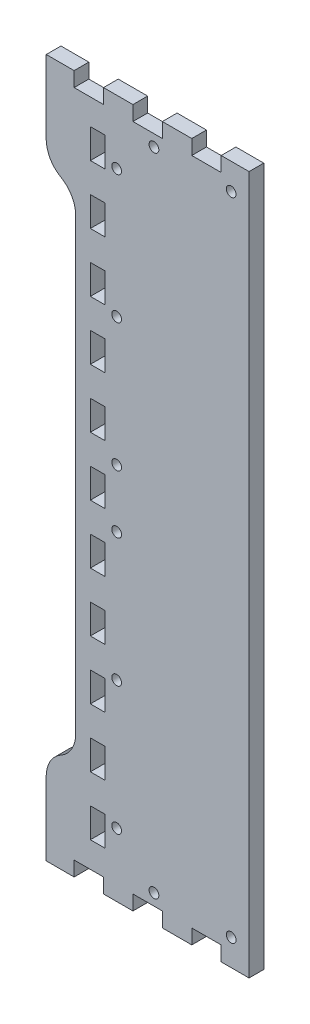
from build123d import *

# Parameters (mm, degrees)
BOSS_EXTRUDE1_DEPTH   = 5.715
F_6_CLEARANCE_HOLE1_D = 3.7973


with BuildPart() as part:
    # Model → Boss-Extrude1 (new body)
    with BuildSketch(Plane.XY):
        Polygon((953.262, 22.8575), (964.099, 22.8575), (964.099, 28.5722), (975.526, 28.5722), (975.526, 22.8575), (986.956, 22.8575), (986.956, 28.5722), (998.386, 28.5722), (998.386, 22.8575), (1009.82, 22.8575), (1009.82, 28.5722), (1021.25, 28.5722), (1021.25, 22.8575), (1032.08, 22.8575), (1032.08, 28.5722), (1032.08, 288.572), (1032.08, 294.287), (1021.25, 294.287), (1021.25, 288.572), (1009.82, 288.572), (1009.82, 294.287), (998.386, 294.287), (998.386, 288.572), (986.956, 288.572), (986.956, 294.287), (975.526, 294.287), (975.526, 288.572), (964.099, 288.572), (964.099, 294.287), (953.262, 294.287), (953.262, 288.572), (953.262, 265.712), (953.262, 265.339), (953.361, 264.218), (953.654, 262.755), (954.133, 261.342), (954.606, 260.321), (954.793, 259.997), (954.888, 259.836), (955.192, 259.36), (955.626, 258.753), (956.098, 258.175), (956.61, 257.631), (957.153, 257.121), (957.732, 256.647), (958.338, 256.211), (958.815, 255.907), (958.977, 255.814), (959.139, 255.721), (959.612, 255.418), (960.222, 254.981), (960.801, 254.507), (961.344, 253.997), (961.856, 253.453), (962.328, 252.876), (962.766, 252.268), (963.069, 251.792), (963.161, 251.63), (963.348, 251.307), (963.824, 250.286), (964.304, 248.874), (964.593, 247.41), (964.692, 246.29), (964.692, 245.915), (964.692, 71.2294), (964.692, 70.8561), (964.593, 69.7357), (964.304, 68.272), (963.824, 66.8595), (963.348, 65.8386), (963.161, 65.5147), (963.069, 65.3535), (962.766, 64.878), (962.328, 64.2705), (961.856, 63.693), (961.344, 63.1486), (960.801, 62.6389), (960.222, 62.1647), (959.612, 61.728), (959.139, 61.4246), (958.977, 61.3311), (958.815, 61.2373), (958.338, 60.9353), (957.732, 60.4986), (957.153, 60.0244), (956.61, 59.5147), (956.098, 58.9703), (955.626, 58.3928), (955.192, 57.7854), (954.888, 57.3098), (954.793, 57.1472), (954.606, 56.8247), (954.133, 55.8038), (953.654, 54.3913), (953.361, 52.9276), (953.262, 51.8072), (953.262, 51.4325), (953.262, 28.5722), align=None)
        Polygon((970.407, 272.872), (970.407, 278.587), (976.122, 278.587), (976.122, 267.158), (970.407, 267.158), align=None, mode=Mode.SUBTRACT)
        Polygon((970.407, 250.012), (970.407, 255.728), (976.122, 255.728), (976.122, 244.297), (970.407, 244.297), align=None, mode=Mode.SUBTRACT)
        Polygon((970.407, 227.153), (970.407, 232.868), (976.122, 232.868), (976.122, 221.437), (970.407, 221.437), align=None, mode=Mode.SUBTRACT)
        Polygon((970.407, 204.293), (970.407, 210.008), (976.122, 210.008), (976.122, 198.578), (970.407, 198.578), align=None, mode=Mode.SUBTRACT)
        Polygon((970.407, 181.433), (970.407, 187.147), (976.122, 187.147), (976.122, 175.718), (970.407, 175.718), align=None, mode=Mode.SUBTRACT)
        Polygon((970.407, 158.572), (970.407, 164.287), (976.122, 164.287), (976.122, 152.858), (970.407, 152.858), align=None, mode=Mode.SUBTRACT)
        Polygon((970.407, 135.712), (970.407, 141.428), (976.122, 141.428), (976.122, 129.997), (970.407, 129.997), align=None, mode=Mode.SUBTRACT)
        Polygon((970.407, 112.853), (970.407, 118.568), (976.122, 118.568), (976.122, 107.137), (970.407, 107.137), align=None, mode=Mode.SUBTRACT)
        Polygon((970.407, 89.9929), (970.407, 95.7076), (976.122, 95.7076), (976.122, 84.2779), (970.407, 84.2779), align=None, mode=Mode.SUBTRACT)
        Polygon((970.407, 67.1326), (970.407, 72.8472), (976.122, 72.8472), (976.122, 61.4179), (970.407, 61.4179), align=None, mode=Mode.SUBTRACT)
        Polygon((970.407, 44.2722), (970.407, 49.9868), (976.122, 49.9868), (976.122, 38.5576), (970.407, 38.5576), align=None, mode=Mode.SUBTRACT)
    extrude(amount=BOSS_EXTRUDE1_DEPTH)

    # #6 Clearance Hole1 (through all)
    with Locations(Plane.XY.offset(5.715)):
        with Locations((1025.122, 284.072), (995.122, 284.072), (980.622, 269.572), (980.622, 219.713875), (980.622, 169.85575), (980.622, 147.28845), (980.622, 97.430325), (980.622, 47.5722), (995.122, 33.0722), (1025.122, 33.0722)):
            Hole(F_6_CLEARANCE_HOLE1_D / 2)


solid = part.part
